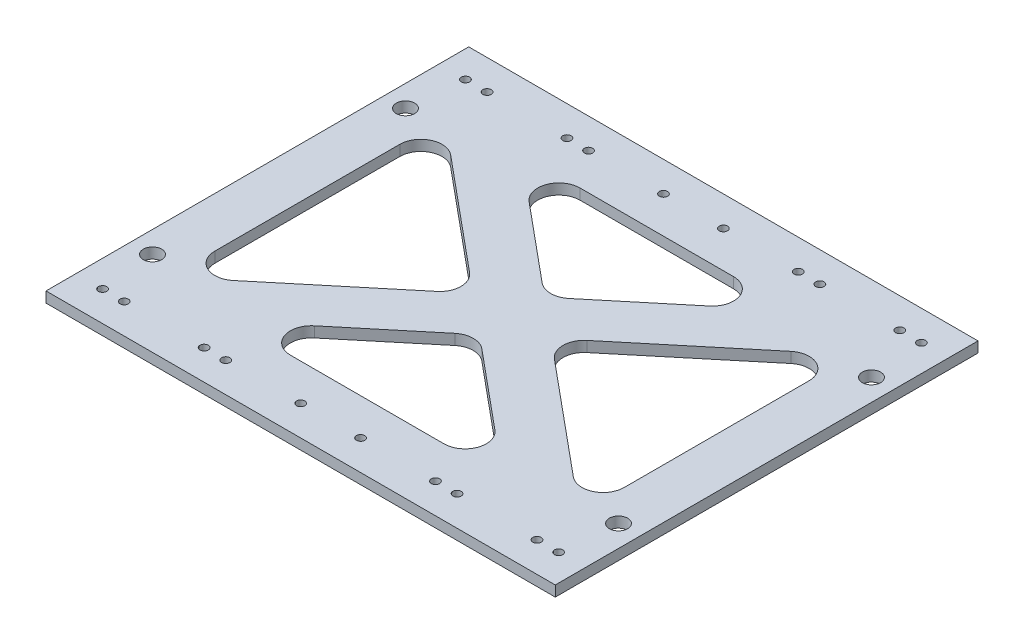
from build123d import *

# Parameters (mm, degrees)
SKETCH1_W             = 153
SKETCH1_H             = 127.000000028
BOSS_EXTRUDE1_DEPTH   = 3.175
M3X0_5_TAPPED_HOLE1_D = 2.5
SKETCH4_R             = 2.75
CUT_EXTRUDE1_DEPTH    = 4.175
CUT_EXTRUDE2_DEPTH    = 4.175


with BuildPart() as part:
    # Sketch1 → Boss-Extrude1 (new body)
    with BuildSketch(Plane(origin=(0, 0, 0), x_dir=(1, 0, 0), z_dir=(0, 1, 0))):
        Rectangle(SKETCH1_W, SKETCH1_H)
    extrude(amount=BOSS_EXTRUDE1_DEPTH)

    # M3x0.5 Tapped Hole1 (through all)
    with Locations(Plane(origin=(0, 3.175, 0), x_dir=(-1, 0, 0), z_dir=(0, 1, 0))):
        with Locations((62, -54.500000014), (38, -54.500000014), (9, -54.500000014), (-9, -54.500000014), (-38, -54.500000014), (-62, -54.500000014), (-62, 54.500000014), (-38, 54.500000014), (-9, 54.500000014), (9, 54.500000014), (38, 54.500000014), (62, 54.500000014), (-31.5, 54.500000014), (-68.5, 54.500000014), (-68.5, -54.500000014), (-31.5, -54.500000014), (31.5, -54.500000014), (68.5, -54.500000014), (31.5, 54.500000014), (68.5, 54.500000014)):
            Hole(M3X0_5_TAPPED_HOLE1_D / 2)

    # Sketch4 → Cut-Extrude1 (cut, through all)
    with BuildSketch(Plane(origin=(0, 3.175, 0), x_dir=(1, 0, 0), z_dir=(0, 1, 0))):
        with Locations(Location((-70, 38, 0), (0, 0, 270))):  # turned: the seam where the file's is
            Circle(SKETCH4_R)
        with Locations(Location((-70, -38, 0), (0, 0, 270))):  # turned: the seam where the file's is
            Circle(SKETCH4_R)
        with Locations(Location((70, -38, 0), (0, 0, 270))):  # turned: the seam where the file's is
            Circle(SKETCH4_R)
        with Locations(Location((70, 38, 0), (0, 0, 270))):  # turned: the seam where the file's is
            Circle(SKETCH4_R)
    extrude(amount=-CUT_EXTRUDE1_DEPTH, mode=Mode.SUBTRACT)

    # Sketch5 → Cut-Extrude2 (cut, through all)
    with BuildSketch(Plane(origin=(0, 3.175, 0), x_dir=(1, 0, 0), z_dir=(0, 1, 0))):
        with BuildLine():
            Line((-23.070812682, 43.500000014), (23.070812682, 43.500000014))
            ThreePointArc((23.070812682, 43.500000014), (29.043622339, 39.30593248), (27.126552604, 32.263951132))
            Line((27.126552604, 32.263951132), (4.055739923, 13.113668706))
            ThreePointArc((4.055739923, 13.113668706), (0, 11.649717588), (-4.055739923, 13.113668706))
            Line((-4.055739923, 13.113668706), (-27.126552604, 32.263951132))
            ThreePointArc((-27.126552604, 32.263951132), (-29.043622339, 39.30593248), (-23.070812682, 43.500000014))
        make_face()
        with BuildLine():
            Line((-61.5, 27.778386997), (-61.5, -27.778386997))
            ThreePointArc((-61.5, -27.778386997), (-57.848939745, -33.526275675), (-51.094260077, -32.66443588))
            Line((-51.094260077, -32.66443588), (-17.628959214, -4.886048882))
            ThreePointArc((-17.628959214, -4.886048882), (-15.334699136, 0), (-17.628959214, 4.886048882))
            Line((-17.628959214, 4.886048882), (-51.094260077, 32.66443588))
            ThreePointArc((-51.094260077, 32.66443588), (-57.848939745, 33.526275675), (-61.5, 27.778386997))
        make_face()
        with BuildLine():
            Line((4.055739923, -13.113668706), (27.126552604, -32.263951132))
            ThreePointArc((27.126552604, -32.263951132), (29.043622339, -39.30593248), (23.070812682, -43.500000014))
            Line((23.070812682, -43.500000014), (-23.070812682, -43.500000014))
            ThreePointArc((-23.070812682, -43.500000014), (-29.043622339, -39.30593248), (-27.126552604, -32.263951132))
            Line((-27.126552604, -32.263951132), (-4.055739923, -13.113668706))
            ThreePointArc((-4.055739923, -13.113668706), (0, -11.649717588), (4.055739923, -13.113668706))
        make_face()
        with BuildLine():
            Line((61.5, 27.778386997), (61.5, -27.778386997))
            ThreePointArc((61.5, -27.778386997), (57.848939745, -33.526275675), (51.094260077, -32.66443588))
            Line((51.094260077, -32.66443588), (17.628959214, -4.886048882))
            ThreePointArc((17.628959214, -4.886048882), (15.334699136, 0), (17.628959214, 4.886048882))
            Line((17.628959214, 4.886048882), (51.094260077, 32.66443588))
            ThreePointArc((51.094260077, 32.66443588), (57.848939745, 33.526275675), (61.5, 27.778386997))
        make_face()
    extrude(amount=-CUT_EXTRUDE2_DEPTH, mode=Mode.SUBTRACT)


solid = part.part
